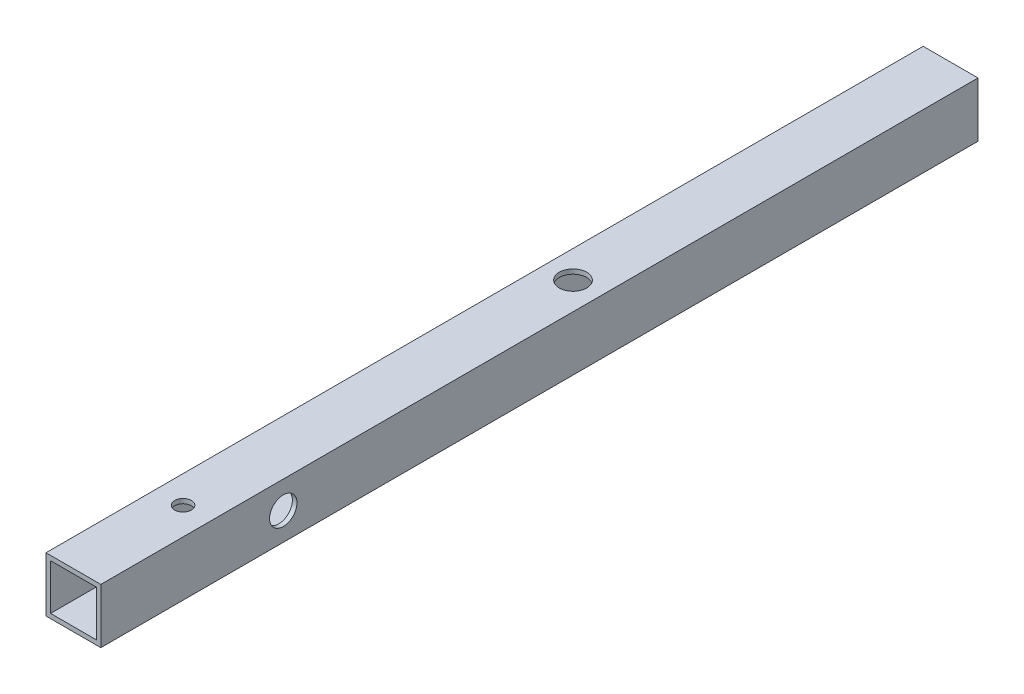
from build123d import *

# Parameters (mm, degrees)
SKETCH1_W                   = 19.05
SKETCH1_H                   = 19.05
SKETCH1_W_2                 = 15.875
SKETCH1_H_2                 = 15.875
BOSS_EXTRUDE1_DEPTH         = 152.4
SKETCH2_R                   = 2.8956
BASEPLATE_MOUNT_HOLE_DEPTH  = 20.05
PS_BRACKET_MOUNT_HOLE_REACH = 21.05
SKETCH3_R                   = 4.7625
CUT_EXTRUDE1_REACH          = 21.05
SKETCH4_R                   = 4.7625
CUT_EXTRUDE2_REACH          = 21.05
SKETCH5_R                   = 4.7625


with BuildPart() as part:
    # Sketch1 → Boss-Extrude1 (new body, symmetric)
    with BuildSketch(Plane(origin=(0, 0, 0), x_dir=(0, -1, 0), z_dir=(0, 0, 1))):
        Rectangle(SKETCH1_W, SKETCH1_H)
        Rectangle(SKETCH1_W_2, SKETCH1_H_2, mode=Mode.SUBTRACT)
    extrude(amount=BOSS_EXTRUDE1_DEPTH, both=True)

    # Sketch2 → Baseplate Mount Hole (cut, through all)
    with BuildSketch(Plane(origin=(0, 9.525, 0), x_dir=(1, 0, 0), z_dir=(0, 1, 0))):
        with Locations((0, -114.3)):
            Circle(SKETCH2_R)
    extrude(amount=-BASEPLATE_MOUNT_HOLE_DEPTH, mode=Mode.SUBTRACT)

    # Sketch3 → PS Bracket Mount Hole (cut, up to next)
    with BuildSketch(Plane.ZY.offset(9.525), mode=Mode.PRIVATE) as ps_bracket_mount_hole_sk1:
        with Locations((-44.45, 0)):
            Circle(SKETCH3_R)
    ps_bracket_mount_hole_tool1 = extrude(ps_bracket_mount_hole_sk1.sketch, amount=-PS_BRACKET_MOUNT_HOLE_REACH, mode=Mode.PRIVATE) & part.part
    add(ps_bracket_mount_hole_tool1.solids().sort_by_distance((-9.525, 0, -44.45))[0], mode=Mode.SUBTRACT)

    # Sketch4 → Cut-Extrude1 (cut, up to next)
    with BuildSketch(Plane(origin=(0, 9.525, 0), x_dir=(1, 0, 0), z_dir=(0, 1, 0)), mode=Mode.PRIVATE) as cut_extrude1_sk1:
        with Locations((0, 21.200533333)):
            Circle(SKETCH4_R)
    cut_extrude1_tool1 = extrude(cut_extrude1_sk1.sketch, amount=-CUT_EXTRUDE1_REACH, mode=Mode.PRIVATE) & part.part
    add(cut_extrude1_tool1.solids().sort_by_distance((0, 9.525, -21.200533))[0], mode=Mode.SUBTRACT)

    # Sketch5 → Cut-Extrude2 (cut, up to next)
    with BuildSketch(Plane(origin=(9.525, 0, 0), x_dir=(0, 0, -1), z_dir=(1, 0, 0)), mode=Mode.PRIVATE) as cut_extrude2_sk1:
        with Locations((-89.0016, 0)):
            Circle(SKETCH5_R)
    cut_extrude2_tool1 = extrude(cut_extrude2_sk1.sketch, amount=-CUT_EXTRUDE2_REACH, mode=Mode.PRIVATE) & part.part
    add(cut_extrude2_tool1.solids().sort_by_distance((9.525, 0, 89.0016))[0], mode=Mode.SUBTRACT)


solid = part.part
